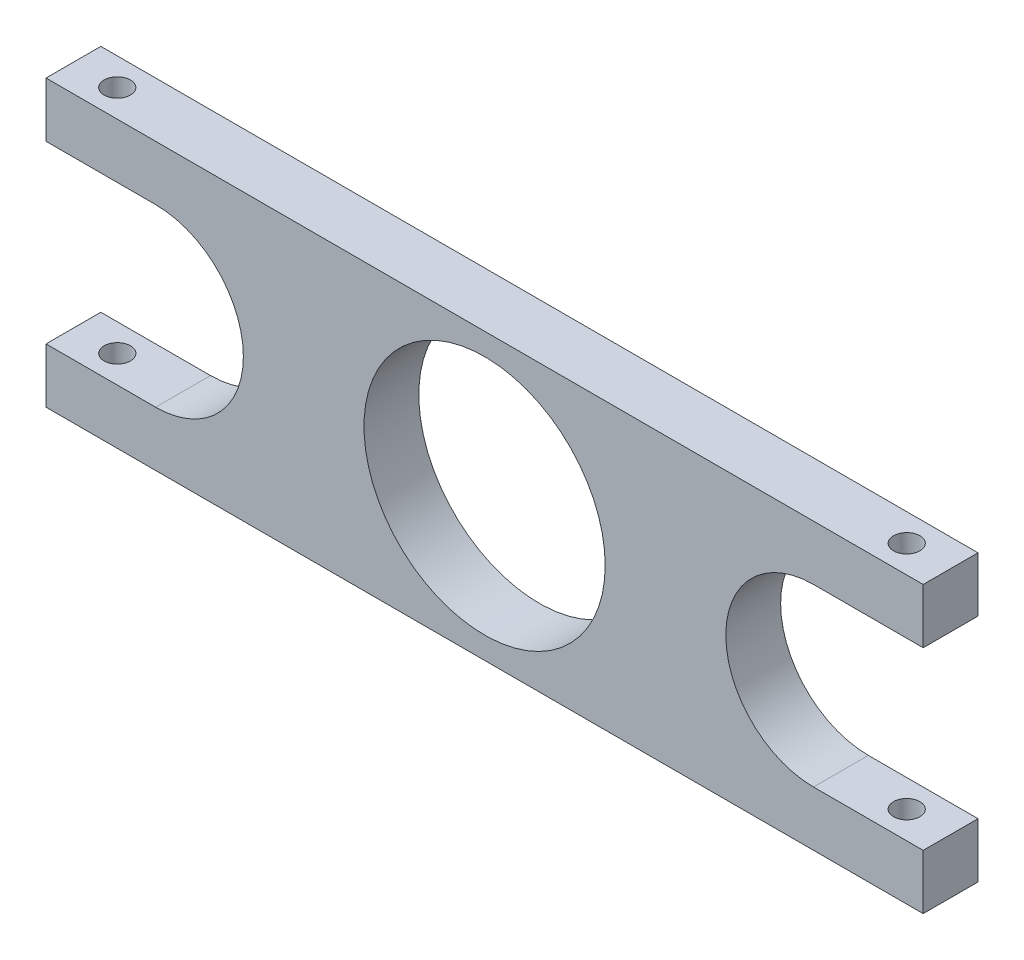
from build123d import *

# Parameters (mm, degrees)
ESQUISSE1_R        = 11
BOSS_EXTRU_1_DEPTH = 5
D_GAGEMENT_M21_D   = 2.4


with BuildPart() as part:
    # Esquisse1 → Boss.-Extru.1 (new body)
    with BuildSketch(Plane.XY):
        with BuildLine():
            Line((0, 0), (80, 0))
            Line((80, 0), (80, 5))
            Line((80, 5), (70, 5))
            ThreePointArc((70, 5), (62, 13), (70, 21))
            Line((70, 21), (80, 21))
            Line((80, 21), (80, 26))
            Line((80, 26), (0, 26))
            Line((0, 26), (0, 21))
            Line((0, 21), (10, 21))
            ThreePointArc((10, 21), (18, 13), (10, 5))
            Line((10, 5), (0, 5))
            Line((0, 5), (0, 0))
        make_face()
        with Locations((40, 13)):
            Circle(ESQUISSE1_R, mode=Mode.SUBTRACT)
    extrude(amount=BOSS_EXTRU_1_DEPTH)

    # Dégagement M21 (through all)
    with Locations(Plane(origin=(0, 26, 0), x_dir=(1, 0, 0), z_dir=(0, 1, 0))):
        with Locations((76, -2.5), (4, -2.5)):
            Hole(D_GAGEMENT_M21_D / 2)


solid = part.part
